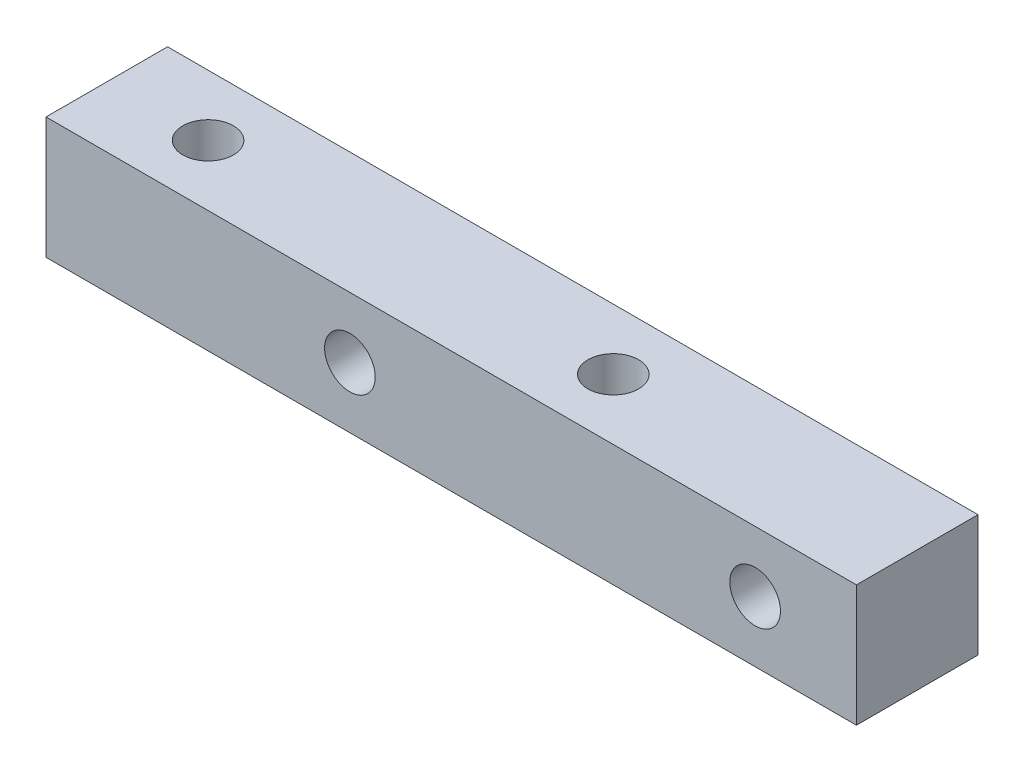
from build123d import *

# Parameters (mm, degrees)
SKETCH1_W           = 40
SKETCH1_H           = 6
SKETCH1_R           = 1.25
BOSS_EXTRUDE1_DEPTH = 6
SKETCH2_R           = 1.25
CUT_EXTRUDE1_DEPTH  = 6


with BuildPart() as part:
    # Sketch1 → Boss-Extrude1 (new body)
    with BuildSketch(Plane(origin=(0, 0, 0), x_dir=(1, 0, 0), z_dir=(0, 1, 0))):
        with Locations((15, 0)):
            Rectangle(SKETCH1_W, SKETCH1_H)
        Circle(SKETCH1_R, mode=Mode.SUBTRACT)
        with Locations((20, 0)):
            Circle(SKETCH1_R, mode=Mode.SUBTRACT)
    extrude(amount=BOSS_EXTRUDE1_DEPTH)

    # Sketch2 → Cut-Extrude1 (cut)
    with BuildSketch(Plane.XY.offset(3)):
        with Locations((10, 3)):
            Circle(SKETCH2_R)
        with Locations((30, 3)):
            Circle(SKETCH2_R)
    extrude(amount=-CUT_EXTRUDE1_DEPTH, mode=Mode.SUBTRACT)


solid = part.part
